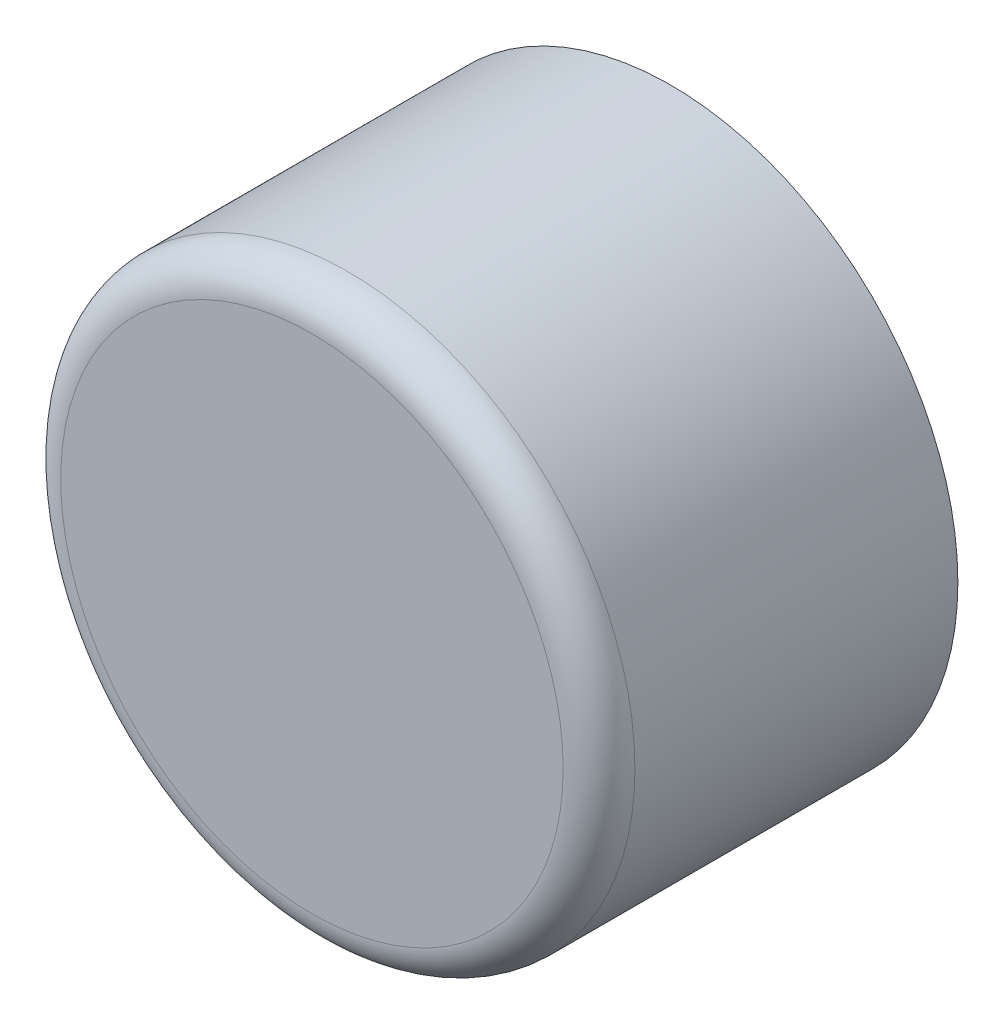
from build123d import *

# Parameters (mm, degrees)
SKETCH1_R           = 80
BOSS_EXTRUDE1_DEPTH = 100
FILLET1_R           = 10


with BuildPart() as part:
    # Sketch1 → Boss-Extrude1 (new body)
    with BuildSketch(Plane.XY):
        Circle(SKETCH1_R)
    extrude(amount=BOSS_EXTRUDE1_DEPTH)

    # Fillet1
    fillet1_edges = [part.edges().sort_by_distance(p)[0] for p in [
        (-80, 0, 100),
    ]]
    fillet(fillet1_edges, radius=FILLET1_R)


solid = part.part
